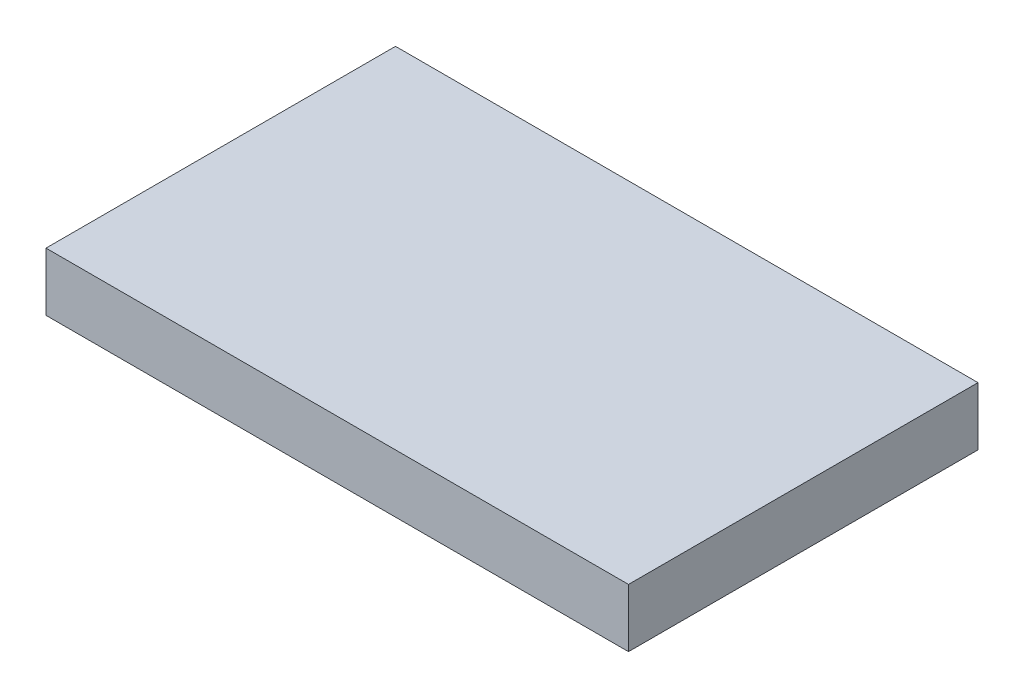
from build123d import *

# Parameters (mm, degrees)
SKETCH1_W           = 127
SKETCH1_H           = 76.2
BOSS_EXTRUDE1_DEPTH = 12.7


with BuildPart() as part:
    # Sketch1 → Boss-Extrude1 (new body)
    with BuildSketch(Plane(origin=(0, 0, 0), x_dir=(1, 0, 0), z_dir=(0, 1, 0))):
        with Locations((63.5, -38.1)):
            Rectangle(SKETCH1_W, SKETCH1_H)
    extrude(amount=BOSS_EXTRUDE1_DEPTH)


solid = part.part
